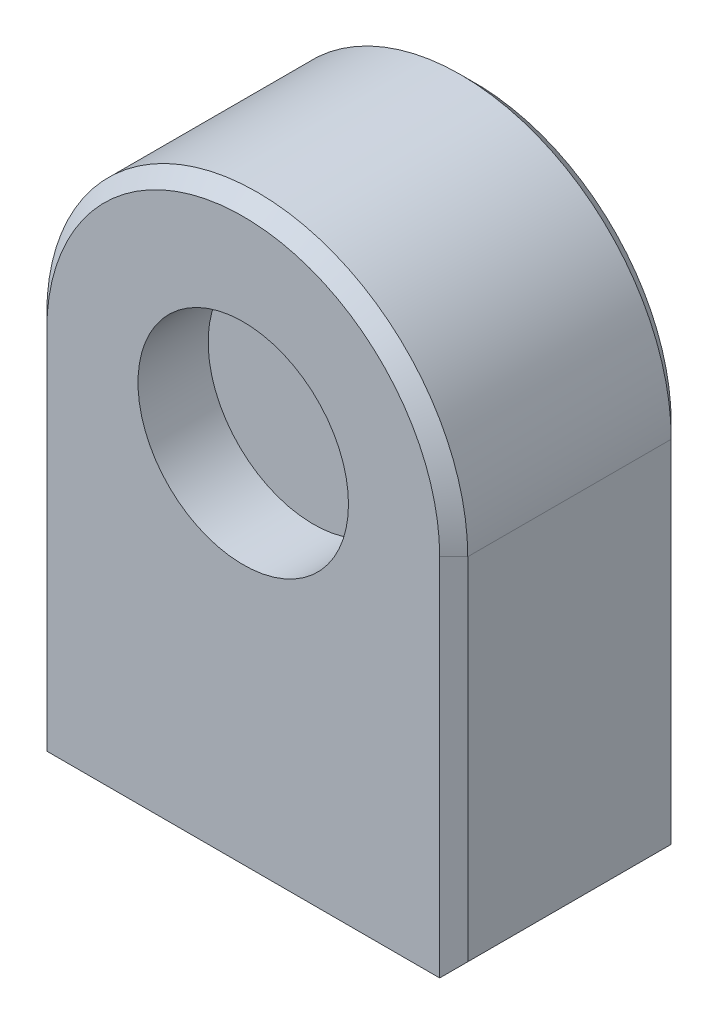
from build123d import *

# Parameters (mm, degrees)
EXTRUDE_1_DEPTH     = 16.5
CHAMFER_1_SIZE      = 1
SKETCH_2_R          = 7.5
CUT_EXTRUDE_1_DEPTH = 5


with BuildPart() as part:
    # 草圖1 → 填料-伸長1 (new body)
    with BuildSketch(Plane.XY):
        with BuildLine():
            Line((-15, 0), (-15, -26))
            Line((-15, -26), (15, -26))
            Line((15, -26), (15, 0))
            ThreePointArc((15, 0), (0, 15), (-15, 0))
        make_face()
    extrude(amount=EXTRUDE_1_DEPTH)

    # 導角1
    chamfer_1_edges = [part.edges().sort_by_distance(p)[0] for p in [
        (15, -13, 16.5),
        (0, 15, 16.5),
        (15, -13, 0),
        (-15, -13, 0),
        (0, 15, 0),
        (-15, -13, 16.5),
        (15, -26, 8.25),
        (-15, -26, 8.25),
    ]]
    chamfer(chamfer_1_edges, length=CHAMFER_1_SIZE)

    # 草圖2 → 除料-伸長1 (cut)
    with BuildSketch(Plane.XY.offset(16.5)):
        Circle(SKETCH_2_R)
    extrude(amount=-CUT_EXTRUDE_1_DEPTH, mode=Mode.SUBTRACT)


solid = part.part
